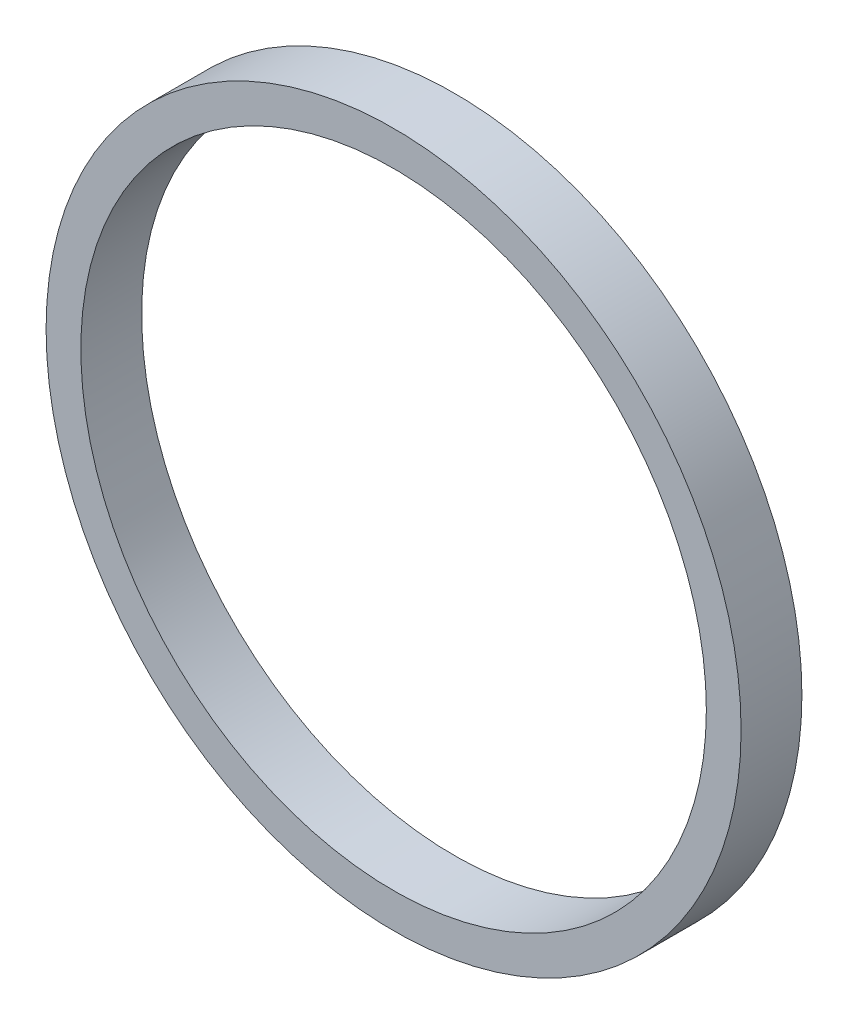
from build123d import *

# Parameters (mm, degrees)
SKETCH1_R           = 40
SKETCH1_R_2         = 36
BOSS_EXTRUDE1_DEPTH = 7


with BuildPart() as part:
    # Sketch1 → Boss-Extrude1 (new body)
    with BuildSketch(Plane.XY):
        Circle(SKETCH1_R)
        Circle(SKETCH1_R_2, mode=Mode.SUBTRACT)
    extrude(amount=BOSS_EXTRUDE1_DEPTH)


solid = part.part
